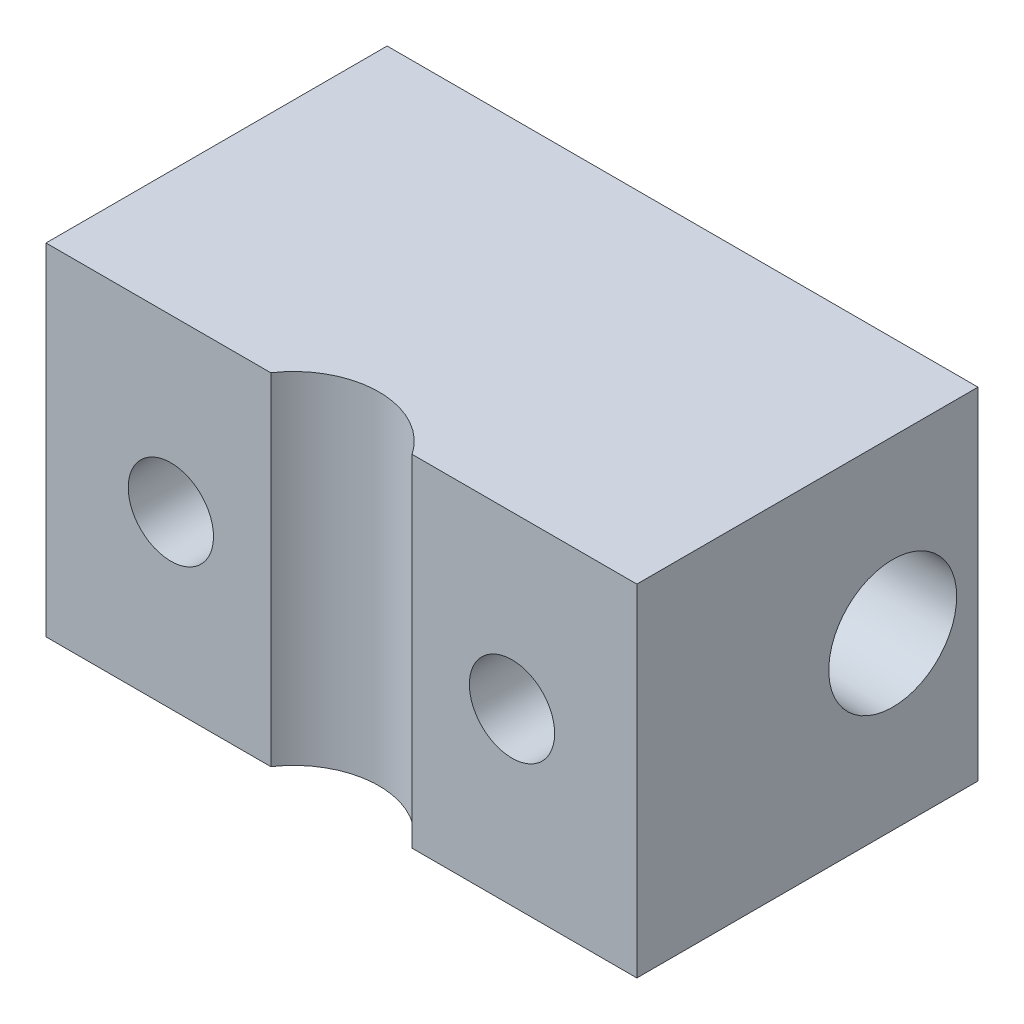
from build123d import *

# Parameters (mm, degrees)
BOSS_EXTRUDE1_DEPTH                = 6.35
F_1_16_0_0625_DIAMETER_HOLE1_D     = 1.5875
F_1_16_0_0625_DIAMETER_HOLE1_DEPTH = 1.5875
F_1_16_0_0625_DIAMETER_HOLE1_TIP   = 0.476933116
F_3_32_0_09375_DIAMETER_HOLE1_D    = 2.38125


with BuildPart() as part:
    # Sketch1 → Boss-Extrude1 (new body)
    with BuildSketch(Plane(origin=(0, 0, 0), x_dir=(1, 0, 0), z_dir=(0, 1, 0))):
        with BuildLine():
            Line((6.814332014, 0), (10.9982, 0))
            Line((10.9982, 0), (10.9982, 6.35))
            Line((10.9982, 6.35), (0, 6.35))
            Line((0, 6.35), (0, 0))
            Line((0, 0), (4.183867986, 0))
            ThreePointArc((4.183867986, 0), (5.4991, 0.6985), (6.814332014, 0))
        make_face()
    extrude(amount=BOSS_EXTRUDE1_DEPTH)

    # 1/16 (0.0625) Diameter Hole1
    with Locations(Plane.XY):
        with Locations((2.3241, 3.175), (8.6741, 3.175)):
            Hole(F_1_16_0_0625_DIAMETER_HOLE1_D / 2, depth=F_1_16_0_0625_DIAMETER_HOLE1_DEPTH)
            with Locations((0, 0, -(F_1_16_0_0625_DIAMETER_HOLE1_DEPTH + F_1_16_0_0625_DIAMETER_HOLE1_TIP / 2))):  # 118° drill point
                Cone(0, F_1_16_0_0625_DIAMETER_HOLE1_D / 2, F_1_16_0_0625_DIAMETER_HOLE1_TIP, mode=Mode.SUBTRACT)

    # 3/32 (0.09375) Diameter Hole1 (through all)
    with Locations(Plane(origin=(10.9982, 0, 0), x_dir=(0, 0, -1), z_dir=(1, 0, 0))):
        with Locations((4.7625, 3.175)):
            Hole(F_3_32_0_09375_DIAMETER_HOLE1_D / 2)


solid = part.part
